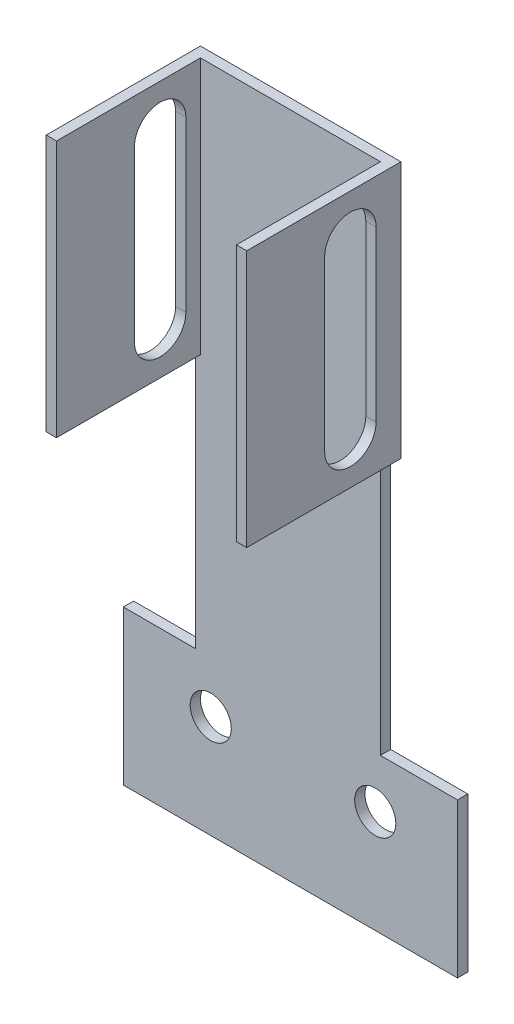
from build123d import *

# Parameters (mm, degrees)
SKETCH_1_R          = 4
EXTRUDE_1_DEPTH     = 2
SKETCH_2_W          = 30
SKETCH_2_H          = 50
EXTRUDE_2_DEPTH     = 2
CUT_EXTRUDE_1_DEPTH = 55


with BuildPart() as part:
    # 草图1 → 凸台-拉伸1 (new body)
    with BuildSketch(Plane.XY):
        Polygon((-27.530821095, -16.070026793), (37.469178905, -16.070026793), (37.469178905, 13.929973207), (22.469178905, 13.929973207), (22.469178905, 113.929973207), (-13.530821095, 113.929973207), (-13.530821095, 13.929973207), (-27.530821095, 13.929973207), align=None)
        with Locations((21.469178905, 3.929973207)):
            Circle(SKETCH_1_R, mode=Mode.SUBTRACT)
        with Locations((-10.530821095, 3.929973207)):
            Circle(SKETCH_1_R, mode=Mode.SUBTRACT)
    extrude(amount=EXTRUDE_1_DEPTH)

    # 草图2 → 凸台-拉伸2 (add)
    with BuildSketch(Plane(origin=(22.469178905, 0, 0), x_dir=(0, 0, -1), z_dir=(1, 0, 0))):
        with Locations((-15, 88.929973207)):
            Rectangle(SKETCH_2_W, SKETCH_2_H)
    extrude_2 = extrude(amount=EXTRUDE_2_DEPTH)

    # 镜向1: 凸台-拉伸2 across plane
    add(extrude_2.mirror(Plane(origin=(4.969178905, 0, 0), x_dir=(0, 0, 1), z_dir=(1, 0, 0))))

    # 草图3 → 切除-拉伸1 (cut)
    with BuildSketch(Plane(origin=(24.469178905, 0, 0), x_dir=(0, 0, -1), z_dir=(1, 0, 0))):
        with BuildLine():
            Line((-14.837360519, 105.36567793), (-14.837360519, 72.494268484))
            ThreePointArc((-14.837360519, 72.494268484), (-9.837360519, 67.494268484), (-4.837360519, 72.494268484))
            Line((-4.837360519, 72.494268484), (-4.837360519, 105.36567793))
            ThreePointArc((-4.837360519, 105.36567793), (-9.837360519, 110.36567793), (-14.837360519, 105.36567793))
        make_face()
    extrude(amount=-CUT_EXTRUDE_1_DEPTH, mode=Mode.SUBTRACT)


solid = part.part
